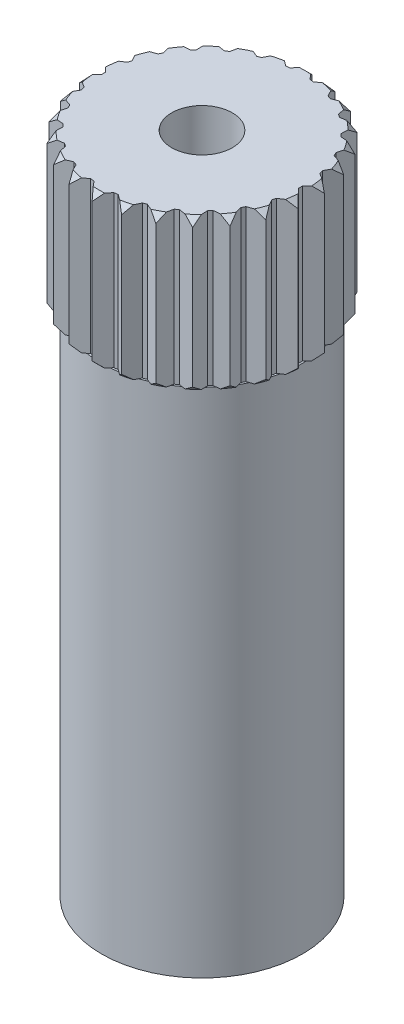
from build123d import *

# Parameters (mm, degrees)
SKETCH12_R          = 2.9
BOSS_EXTRUDE4_DEPTH = 13.5
SKETCH13_R          = 2.6
BOSS_EXTRUDE5_DEPTH = 4
BOSS_EXTRUDE6_DEPTH = 17.5
CIRPATTERN1_COUNT   = 26
SKETCH16_R          = 0.8
CUT_EXTRUDE1_DEPTH  = 4
SKETCH17_W          = 0.25
SKETCH17_H          = 13.5


with BuildPart() as part:
    # Sketch12 → Boss-Extrude4 (new body)
    with BuildSketch(Plane(origin=(0, 0, 0), x_dir=(1, 0, 0), z_dir=(0, 1, 0))):
        Circle(SKETCH12_R)
    extrude(amount=BOSS_EXTRUDE4_DEPTH)

    # Sketch13 → Boss-Extrude5 (add)
    with BuildSketch(Plane(origin=(0, 13.5, 0), x_dir=(1, 0, 0), z_dir=(0, 1, 0))):
        Circle(SKETCH13_R)
    extrude(amount=BOSS_EXTRUDE5_DEPTH)

    # Sketch14 → Boss-Extrude6 (add)
    with BuildSketch(Plane(origin=(0, 17.5, 0), x_dir=(1, 0, 0), z_dir=(0, 1, 0))):
        with BuildLine():
            Line((0, 2.9), (-0.262912611, 2.586672952))
            ThreePointArc((-0.262912611, 2.586672952), (0, 2.6), (0.262912611, 2.586672952))
            Line((0.262912611, 2.586672952), (0, 2.9))
        make_face()
    boss_extrude6 = extrude(amount=-BOSS_EXTRUDE6_DEPTH)

    # CirPattern1: Boss-Extrude6 ×26 about axis
    cirpattern1_axis = Axis((0, 0, 0), (0, 1, 0))
    for i in range(1, CIRPATTERN1_COUNT):
        add(boss_extrude6.rotate(cirpattern1_axis, i * 360 / CIRPATTERN1_COUNT))

    # Sketch15 → Cut-Revolve1 (revolve, cut)
    with BuildSketch(Plane(origin=(0, 0, 0), x_dir=(0, 0, -1), z_dir=(1, 0, 0))):
        Polygon((2.9, 17.323223305), (2.9, 17.5), (2.723223305, 17.5), align=None)
    cut_revolve1 = revolve(axis=Axis((0, 17.5, 0), (0, -1, 0)), mode=Mode.SUBTRACT)

    # Sketch16 → Cut-Extrude1 (cut)
    with BuildSketch(Plane(origin=(0, 17.5, 0), x_dir=(1, 0, 0), z_dir=(0, 1, 0))):
        Circle(SKETCH16_R)
    extrude(amount=-CUT_EXTRUDE1_DEPTH, mode=Mode.SUBTRACT)

    # Sketch17 → Cut-Revolve2 (revolve, cut)
    with BuildSketch(Plane.XY):
        with Locations((2.775, 6.75)):
            Rectangle(SKETCH17_W, SKETCH17_H)
    revolve(axis=Axis((0, 13.5, 0), (0, -1, 0)), mode=Mode.SUBTRACT)

    # Mirror1: Cut-Revolve1 across plane
    add(cut_revolve1.mirror(Plane.ZX.offset(15.5)), mode=Mode.SUBTRACT)


solid = part.part
